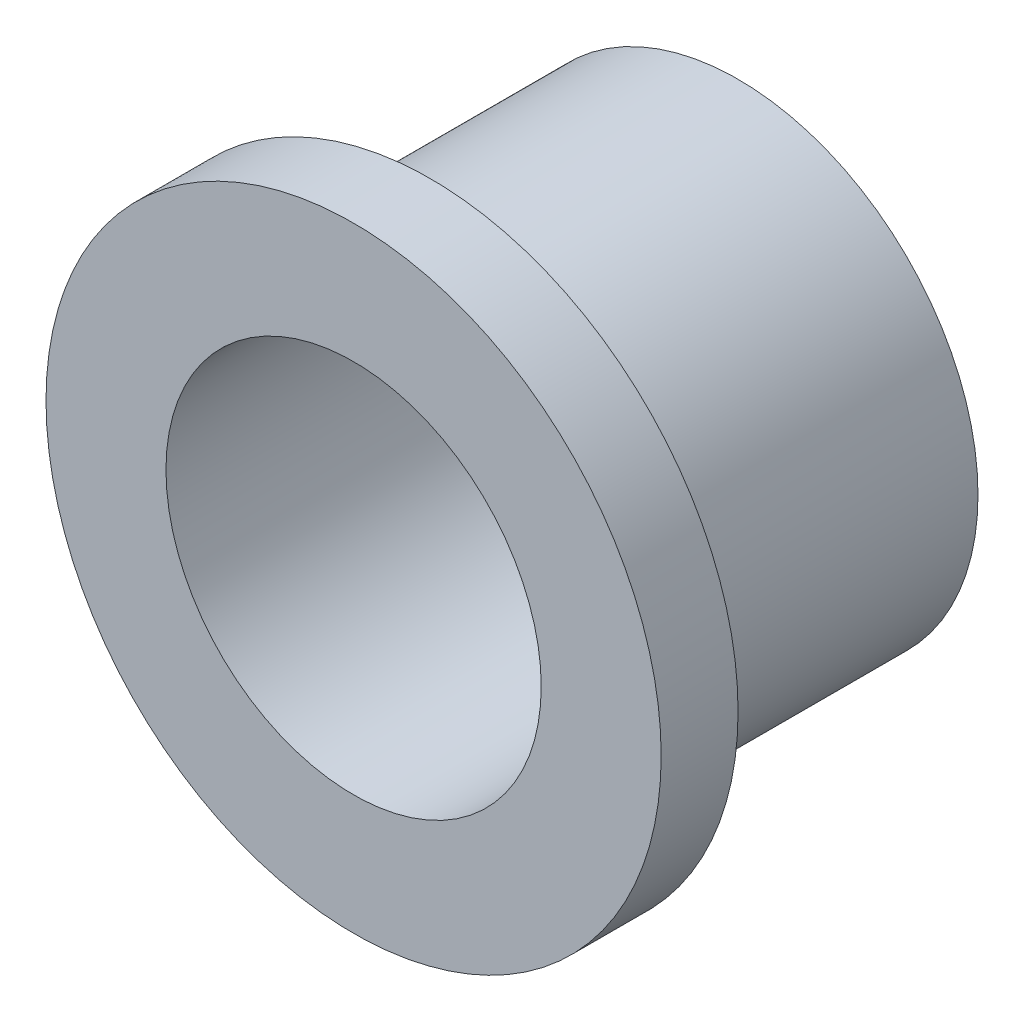
from build123d import *

# Parameters (mm, degrees)
SKETCH1_R           = 3.9
BOSS_EXTRUDE1_DEPTH = 5
SKETCH2_R           = 5
BOSS_EXTRUDE2_DEPTH = 1.25
SKETCH3_R           = 3.05
CUT_EXTRUDE2_DEPTH  = 7.25


with BuildPart() as part:
    # Sketch1 → Boss-Extrude1 (new body)
    with BuildSketch(Plane.XY):
        Circle(SKETCH1_R)
    extrude(amount=BOSS_EXTRUDE1_DEPTH)

    # Sketch2 → Boss-Extrude2 (add)
    with BuildSketch(Plane.XY.offset(5)):
        Circle(SKETCH2_R)
    extrude(amount=BOSS_EXTRUDE2_DEPTH)

    # Sketch3 → Cut-Extrude2 (cut, through all)
    with BuildSketch(Plane(origin=(0, 0, 0), x_dir=(-1, 0, 0), z_dir=(0, 0, -1))):
        Circle(SKETCH3_R)
    extrude(amount=-CUT_EXTRUDE2_DEPTH, mode=Mode.SUBTRACT)


solid = part.part
